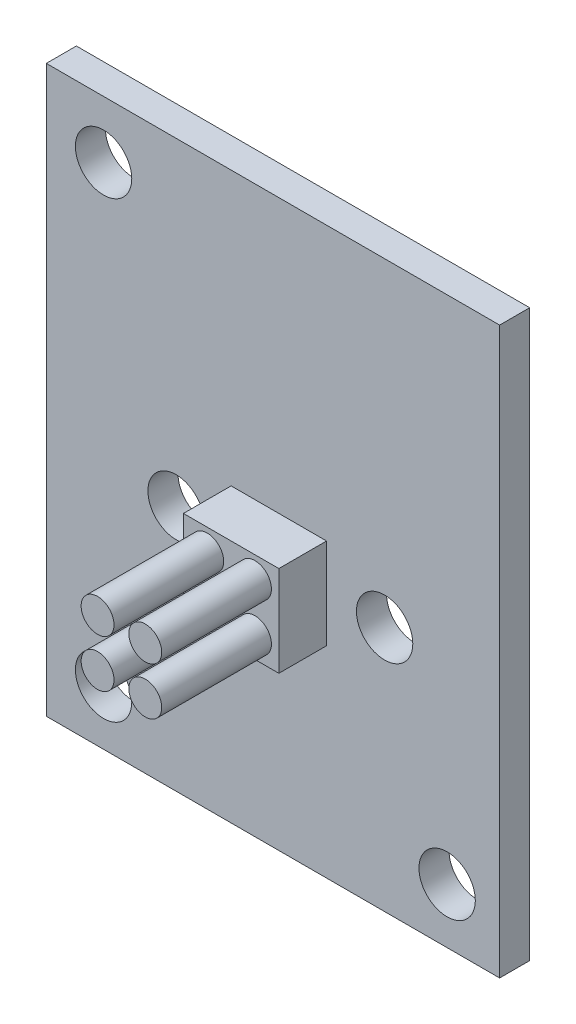
from build123d import *

# Parameters (mm, degrees)
SKETCH1_W           = 24.13
SKETCH1_H           = 30.099
SKETCH1_R           = 1.5
SKETCH1_R_2         = 0.875
BOSS_EXTRUDE1_DEPTH = 1.6
SKETCH1_19_W        = 5.08
SKETCH1_19_H        = 4.83
BOSS_EXTRUDE2_DEPTH = 2.54
BOSS_EXTRUDE3_START = 8.38
SKETCH1_20_R        = 0.875
BOSS_EXTRUDE3_DEPTH = 8.38


with BuildPart() as part:
    # Sketch1 → Boss-Extrude1 (new body)
    with BuildSketch(Plane.XY):
        with Locations((12.065, 15.0495)):
            Rectangle(SKETCH1_W, SKETCH1_H)
        with Locations((3.048, 2.921)):
            Circle(SKETCH1_R, mode=Mode.SUBTRACT)
        with Locations((6.908038, 13.09497)):
            Circle(SKETCH1_R, mode=Mode.SUBTRACT)
        with Locations((21.336, 2.921)):
            Circle(SKETCH1_R, mode=Mode.SUBTRACT)
        with Locations((18.008092, 13.09497)):
            Circle(SKETCH1_R, mode=Mode.SUBTRACT)
        with Locations((3.048, 27.051)):
            Circle(SKETCH1_R, mode=Mode.SUBTRACT)
        with Locations((11.107928, 11.854942)):
            Circle(SKETCH1_R_2, mode=Mode.SUBTRACT)
        with Locations((11.107928, 14.394942)):
            Circle(SKETCH1_R_2, mode=Mode.SUBTRACT)
        with Locations((13.647928, 11.854942)):
            Circle(SKETCH1_R_2, mode=Mode.SUBTRACT)
        with Locations((13.647928, 14.394942)):
            Circle(SKETCH1_R_2, mode=Mode.SUBTRACT)
    extrude(amount=-BOSS_EXTRUDE1_DEPTH)

    # Sketch1_19 → Boss-Extrude2 (add)
    with BuildSketch(Plane.XY):
        with Locations((12.377928, 13.124942)):
            Rectangle(SKETCH1_19_W, SKETCH1_19_H)
    extrude(amount=BOSS_EXTRUDE2_DEPTH)

    # Sketch1_20 → Boss-Extrude3 (add)
    with BuildSketch(Plane.XY.offset(BOSS_EXTRUDE3_START)):
        with Locations((11.107928, 14.394942)):
            Circle(SKETCH1_20_R)
        with Locations((13.647928, 14.394942)):
            Circle(SKETCH1_20_R)
        with Locations((11.107928, 11.854942)):
            Circle(SKETCH1_20_R)
        with Locations((13.647928, 11.854942)):
            Circle(SKETCH1_20_R)
    extrude(amount=-BOSS_EXTRUDE3_DEPTH)


solid = part.part
